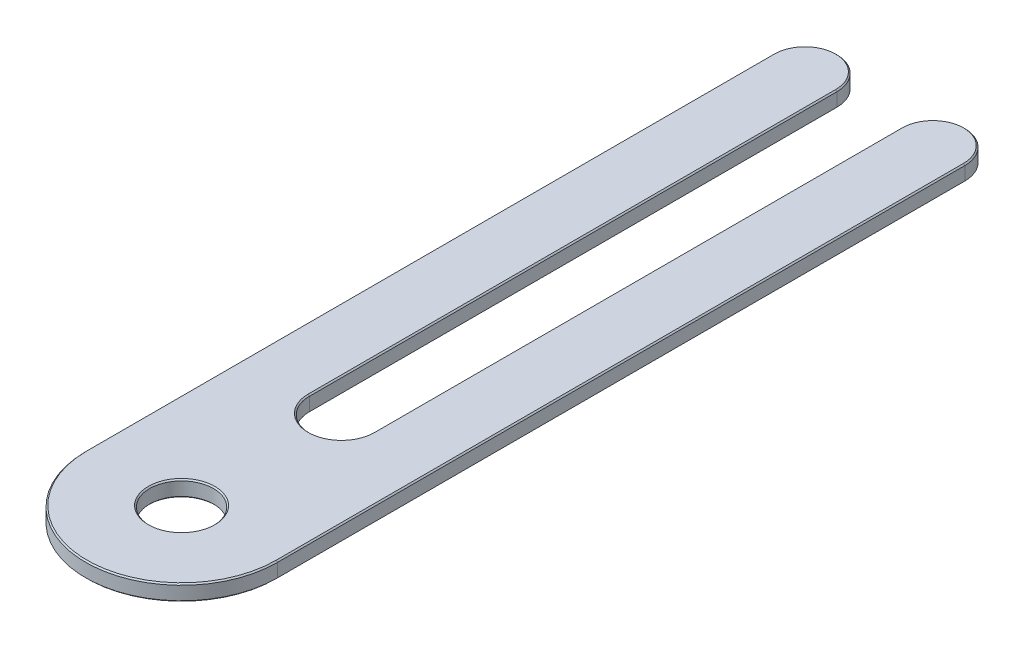
from build123d import *

# Parameters (mm, degrees)
SKETCH1_R          = 6.35
BASE_EXTRUDE_DEPTH = 1.5875
CHAMFER1_SIZE      = 0.254


with BuildPart() as part:
    # Sketch1 → Base-Extrude (new body, symmetric)
    with BuildSketch(Plane(origin=(0, 0, 0), x_dir=(1, 0, 0), z_dir=(0, 1, 0))):
        with BuildLine():
            Line((6.35, 0), (6.35, 104.775))
            ThreePointArc((6.35, 104.775), (12.7, 111.125), (19.05, 104.775))
            Line((19.05, 104.775), (19.05, -31.75))
            ThreePointArc((19.05, -31.75), (0, -50.8), (-19.05, -31.75))
            Line((-19.05, -31.75), (-19.05, 104.775))
            ThreePointArc((-19.05, 104.775), (-12.7, 111.125), (-6.35, 104.775))
            Line((-6.35, 104.775), (-6.35, 0))
            ThreePointArc((-6.35, 0), (0, -6.35), (6.35, 0))
        make_face()
        with Locations(Location((0, -31.75, 0), (0, 0, 270))):  # turned: the seam where the file's is
            Circle(SKETCH1_R, mode=Mode.SUBTRACT)
    extrude(amount=BASE_EXTRUDE_DEPTH, both=True)

    # Chamfer1
    chamfer1_edges = [part.edges().sort_by_distance(p)[0] for p in [
        (-12.7, 1.5875, -111.125),
        (-6.35, -1.5875, -52.3875),
        (0, -1.5875, 6.35),
        (-19.05, 1.5875, -36.5125),
        (0, 1.5875, 50.8),
        (19.05, 1.5875, -36.5125),
        (0, -1.5875, 25.4),
        (0, 1.5875, 25.4),
        (12.7, 1.5875, -111.125),
        (6.35, 1.5875, -52.3875),
        (0, 1.5875, 6.35),
        (-6.35, 1.5875, -52.3875),
        (6.35, -1.5875, -52.3875),
        (12.7, -1.5875, -111.125),
        (19.05, -1.5875, -36.5125),
        (0, -1.5875, 50.8),
        (-19.05, -1.5875, -36.5125),
        (-12.7, -1.5875, -111.125),
    ]]
    chamfer(chamfer1_edges, length=CHAMFER1_SIZE)


solid = part.part
